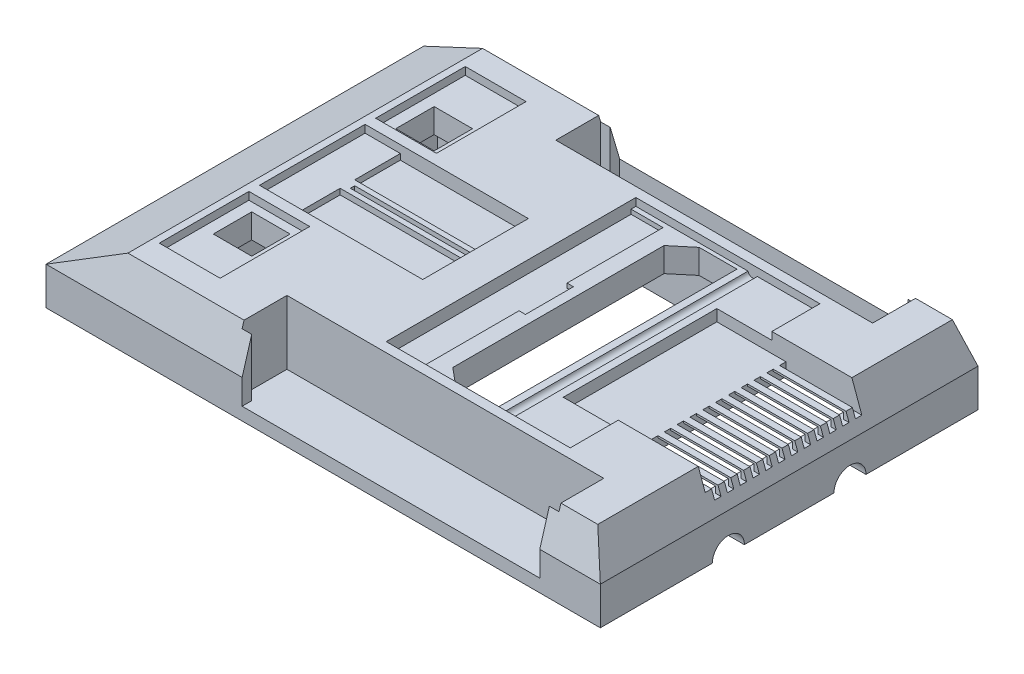
from build123d import *

# Parameters (mm, degrees)
SKETCH1_W           = 219.964
SKETCH1_H           = 149.86
BOSS_EXTRUDE1_DEPTH = 14.986
SKETCH2_W           = 219.964
SKETCH2_H           = 149.86
SKETCH3_W           = 186.436
SKETCH3_H           = 140.716
SKETCH4_W           = 24.13
SKETCH4_H           = 35.56
CUT_EXTRUDE1_DEPTH  = 3.048
SKETCH5_W           = 64.77
SKETCH5_H           = 41.91
CUT_EXTRUDE2_DEPTH  = 3.048
SKETCH10_W          = 125.73
SKETCH10_H          = 17.78
CUT_EXTRUDE5_DEPTH  = 25.4
CUT_EXTRUDE7_DEPTH  = 3.048
SKETCH16_W          = 59.69
SKETCH16_H          = 60.96
CUT_EXTRUDE8_DEPTH  = 7.62
CUT_EXTRUDE9_DEPTH  = 4.826
CUT_EXTRUDE10_DEPTH = 31.48
SKETCH19_W          = 31.75
SKETCH19_H          = 2.54
CUT_EXTRUDE11_DEPTH = 10.922
LPATTERN1_COUNT     = 12
LPATTERN1_PITCH     = 5.08
SKETCH20_W          = 27.94
SKETCH20_H          = 2.54
CUT_EXTRUDE12_DEPTH = 60.96
SKETCH25_W          = 50.8
SKETCH25_H          = 18.0848
SKETCH25_H_2        = 18.034
CUT_EXTRUDE14_DEPTH = 5.334
SKETCH21_W          = 46.99
SKETCH21_H          = 1.7272
CUT_EXTRUDE13_DEPTH = 31.48
SKETCH29_W          = 182.88
SKETCH29_H          = 101.6
CUT_EXTRUDE18_DEPTH = 17.78
SKETCH30_W          = 15.24
SKETCH30_H          = 15.24
CUT_EXTRUDE19_DEPTH = 31.48
SKETCH32_W          = 25.4
SKETCH32_H          = 60.96
CUT_EXTRUDE20_DEPTH = 20.32
SKETCH33_R          = 6.35
CUT_EXTRUDE21_DEPTH = 19.05
SKETCH34_R          = 1.905
CUT_EXTRUDE22_DEPTH = 99.06
SKETCH35_W          = 118.11
SKETCH35_H          = 6.35
CUT_EXTRUDE23_DEPTH = 25.4


with BuildPart() as part:
    # Sketch1 → Boss-Extrude1 (new body)
    with BuildSketch(Plane(origin=(0, 0, 0), x_dir=(1, 0, 0), z_dir=(0, 1, 0))):
        with Locations((-109.982, -74.93)):
            Rectangle(SKETCH1_W, SKETCH1_H)
    extrude(amount=BOSS_EXTRUDE1_DEPTH)

    # Sketch2 → Loft1 section 0
    with BuildSketch(Plane(origin=(0, 14.986, 0), x_dir=(1, 0, 0), z_dir=(0, 1, 0))):
        with Locations((-109.982, -74.93)):
            Rectangle(SKETCH2_W, SKETCH2_H)
    # Sketch3 → Loft1 section 1
    with BuildSketch(Plane(origin=(0, 30.48, 0), x_dir=(1, 0, 0), z_dir=(0, 1, 0))):
        with Locations((-98.806, -74.93)):
            Rectangle(SKETCH3_W, SKETCH3_H)
    loft()

    # Sketch4 → Cut-Extrude1 (cut)
    with BuildSketch(Plane(origin=(0, 30.48, 0), x_dir=(1, 0, 0), z_dir=(0, 1, 0))):
        with Locations((-177.165, -117.856)):
            Rectangle(SKETCH4_W, SKETCH4_H)
        with Locations((-177.165, -32.004)):
            Rectangle(SKETCH4_W, SKETCH4_H)
    extrude(amount=-CUT_EXTRUDE1_DEPTH, mode=Mode.SUBTRACT)

    # Sketch5 → Cut-Extrude2 (cut)
    with BuildSketch(Plane(origin=(0, 30.48, 0), x_dir=(1, 0, 0), z_dir=(0, 1, 0))):
        with Locations((-156.845, -74.93)):
            Rectangle(SKETCH5_W, SKETCH5_H)
    extrude(amount=-CUT_EXTRUDE2_DEPTH, mode=Mode.SUBTRACT)

    # Sketch10 → Cut-Extrude5 (cut)
    with BuildSketch(Plane(origin=(0, 30.48, 0), x_dir=(1, 0, 0), z_dir=(0, 1, 0))):
        with Locations((-83.084052156, -137.16121158)):
            Rectangle(SKETCH10_W, SKETCH10_H)
        with Locations((-83.084052156, -12.69878842)):
            Rectangle(SKETCH10_W, SKETCH10_H)
    extrude(amount=-CUT_EXTRUDE5_DEPTH, mode=Mode.SUBTRACT)

    # Sketch15 → Cut-Extrude7 (cut)
    with BuildSketch(Plane(origin=(0, 30.48, 0), x_dir=(1, 0, 0), z_dir=(0, 1, 0))):
        Polygon((-110.363, -25.4), (-37.338, -25.4), (-37.338, -44.45), (-59.182, -44.45), (-59.182, -105.41), (-37.338, -105.41), (-37.338, -124.46), (-110.363, -124.46), align=None)
    extrude(amount=-CUT_EXTRUDE7_DEPTH, mode=Mode.SUBTRACT)

    # Sketch16 → Cut-Extrude8 (cut)
    with BuildSketch(Plane(origin=(0, 30.48, 0), x_dir=(1, 0, 0), z_dir=(0, 1, 0))):
        with Locations((-29.337, -74.93)):
            Rectangle(SKETCH16_W, SKETCH16_H)
    extrude(amount=-CUT_EXTRUDE8_DEPTH, mode=Mode.SUBTRACT)

    # Sketch17 → Cut-Extrude9 (cut)
    with BuildSketch(Plane(origin=(0, 30.48, 0), x_dir=(1, 0, 0), z_dir=(0, 1, 0))):
        Polygon((-110.363, -27.30378842), (-97.663, -27.30378842), (-97.663, -65.40378842), (-95.123, -65.40378842), (-95.123, -84.45378842), (-97.663, -84.45378842), (-97.663, -122.55378842), (-110.363, -122.55378842), align=None)
    extrude(amount=-CUT_EXTRUDE9_DEPTH, mode=Mode.SUBTRACT)

    # Sketch18 → Cut-Extrude10 (cut, through all)
    with BuildSketch(Plane(origin=(0, 30.48, 0), x_dir=(1, 0, 0), z_dir=(0, 1, 0))):
        Polygon((-83.70995219, -26.92278842), (-91.313, -33.27278842), (-91.313, -117.09278842), (-83.70995219, -123.44278842), (-68.72395219, -123.44278842), (-68.72395219, -26.92278842), align=None)
    extrude(amount=-CUT_EXTRUDE10_DEPTH, mode=Mode.SUBTRACT)

    # Sketch19 → Cut-Extrude11 (cut)
    with BuildSketch(Plane(origin=(0, 30.48, 0), x_dir=(1, 0, 0), z_dir=(0, 1, 0))):
        with Locations((-15.875, -45.72)):
            Rectangle(SKETCH19_W, SKETCH19_H)
    cut_extrude11 = extrude(amount=-CUT_EXTRUDE11_DEPTH, mode=Mode.SUBTRACT)

    # LPattern1: Cut-Extrude11 ×12
    with Locations(*[(0, 0, i * LPATTERN1_PITCH) for i in range(1, LPATTERN1_COUNT)]):
        add(cut_extrude11, mode=Mode.SUBTRACT)

    # Sketch20 → Cut-Extrude12 (cut)
    with BuildSketch(Plane.XY.offset(44.45)):
        with Locations((-17.78, 20.828)):
            Rectangle(SKETCH20_W, SKETCH20_H)
    extrude(amount=CUT_EXTRUDE12_DEPTH, mode=Mode.SUBTRACT)

    # Sketch25 → Cut-Extrude14 (cut)
    with BuildSketch(Plane(origin=(0, 30.48, 0), x_dir=(1, 0, 0), z_dir=(0, 1, 0))):
        with Locations((-149.86, -63.0174)):
            Rectangle(SKETCH25_W, SKETCH25_H)
        with Locations((-149.86, -86.868)):
            Rectangle(SKETCH25_W, SKETCH25_H_2)
    extrude(amount=-CUT_EXTRUDE14_DEPTH, mode=Mode.SUBTRACT)

    # Sketch21 → Cut-Extrude13 (cut, through all)
    with BuildSketch(Plane(origin=(0, 30.48, 0), x_dir=(1, 0, 0), z_dir=(0, 1, 0))):
        with Locations((-149.733, -74.9554)):
            Rectangle(SKETCH21_W, SKETCH21_H)
    extrude(amount=-CUT_EXTRUDE13_DEPTH, mode=Mode.SUBTRACT)

    # Sketch29 → Cut-Extrude18 (cut)
    with BuildSketch(Plane(origin=(0, 0, 0), x_dir=(1, 0, 0), z_dir=(0, 1, 0))):
        with Locations((-98.985433164, -74.93)):
            Rectangle(SKETCH29_W, SKETCH29_H)
    extrude(amount=CUT_EXTRUDE18_DEPTH, mode=Mode.SUBTRACT)

    # Sketch30 → Cut-Extrude19 (cut, through all)
    with BuildSketch(Plane(origin=(0, 30.48, 0), x_dir=(1, 0, 0), z_dir=(0, 1, 0))):
        with Locations((-177.071342222, -38.735)):
            Rectangle(SKETCH30_W, SKETCH30_H)
        with Locations((-177.071342222, -111.125)):
            Rectangle(SKETCH30_W, SKETCH30_H)
    extrude(amount=-CUT_EXTRUDE19_DEPTH, mode=Mode.SUBTRACT)

    # Sketch32 → Cut-Extrude20 (cut)
    with BuildSketch(Plane(origin=(0, 0, 0), x_dir=(1, 0, 0), z_dir=(0, 1, 0))):
        with Locations((-19.05, -74.93)):
            Rectangle(SKETCH32_W, SKETCH32_H)
    extrude(amount=CUT_EXTRUDE20_DEPTH, mode=Mode.SUBTRACT)

    # Sketch33 → Cut-Extrude21 (cut)
    with BuildSketch(Plane(origin=(0, 0, 0), x_dir=(0, 0, -1), z_dir=(1, 0, 0))):
        with Locations((-99.06, 0)):
            Circle(SKETCH33_R)
        with Locations((-50.8, 0)):
            Circle(SKETCH33_R)
    extrude(amount=-CUT_EXTRUDE21_DEPTH, mode=Mode.SUBTRACT)

    # Sketch34 → Cut-Extrude22 (cut)
    with BuildSketch(Plane.XY.offset(25.4)):
        with Locations((-64.008, 27.893560757)):
            Circle(SKETCH34_R)
    extrude(amount=CUT_EXTRUDE22_DEPTH, mode=Mode.SUBTRACT)

    # Sketch35 → Cut-Extrude23 (cut)
    with BuildSketch(Plane(origin=(0, 30.48, 0), x_dir=(1, 0, 0), z_dir=(0, 1, 0))):
        with Locations((-83.084052156, -146.685)):
            Rectangle(SKETCH35_W, SKETCH35_H)
        with Locations((-83.084052156, -3.2258)):
            Rectangle(SKETCH35_W, SKETCH35_H)
    extrude(amount=-CUT_EXTRUDE23_DEPTH, mode=Mode.SUBTRACT)


solid = part.part
